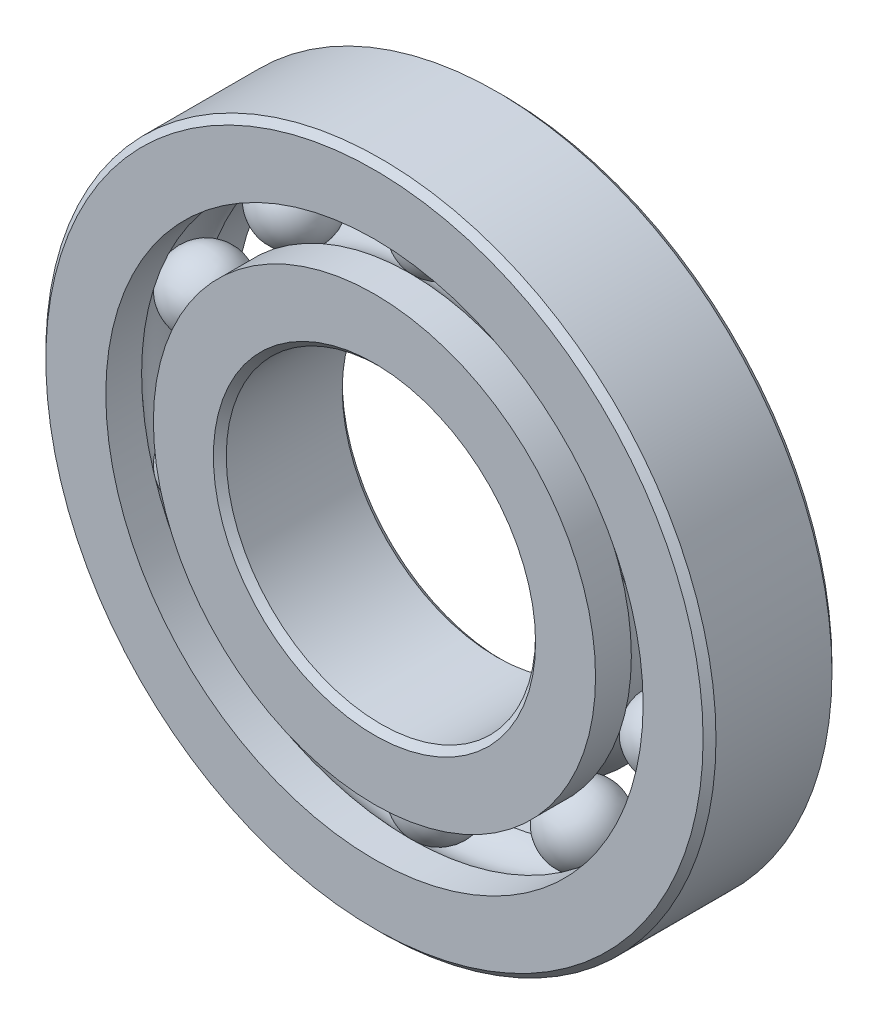
from build123d import *

# Parameters (mm, degrees)
CIRPATTERN1_COUNT = 10


with BuildPart() as part:
    # Sketch1 → Revolve1 (revolve)
    with BuildSketch(Plane(origin=(0, 0, 0), x_dir=(0, 0, -1), z_dir=(1, 0, 0)), mode=Mode.PRIVATE) as revolve1_sk:
        with BuildLine():
            Line((3.571875, 20.6375), (-3.571875, 20.6375))
            Line((-3.571875, 20.6375), (-3.96875, 20.240625))
            Line((-3.96875, 20.240625), (-3.96875, 16.546634615))
            Line((-3.96875, 16.546634615), (-1.763888889, 16.546634615))
            ThreePointArc((-1.763888889, 16.546634615), (0, 17.374425982), (1.763888889, 16.546634615))
            Line((1.763888889, 16.546634615), (3.96875, 16.546634615))
            Line((3.96875, 16.546634615), (3.96875, 20.240625))
            Line((3.96875, 20.240625), (3.571875, 20.6375))
        make_face()
    revolve(revolve1_sk.sketch.rotate(Axis((0, 0, 3.96875), (0, 0, -1)), 90), axis=Axis((0, 0, 3.96875), (0, 0, -1)))  # turned: the seam where the file's is


with BuildPart() as body_2:
    # Sketch3 → Revolve3 (revolve)
    with BuildSketch(Plane(origin=(0, 0, 0), x_dir=(0, 0, -1), z_dir=(1, 0, 0)), mode=Mode.PRIVATE) as revolve3_sk:
        with BuildLine():
            Line((-3.96875, 13.615865385), (-1.763888889, 13.615865385))
            ThreePointArc((-1.763888889, 13.615865385), (0, 12.788074018), (1.763888889, 13.615865385))
            Line((1.763888889, 13.615865385), (3.96875, 13.615865385))
            Line((3.96875, 13.615865385), (3.96875, 9.921875))
            Line((3.96875, 9.921875), (3.571875, 9.525))
            Line((3.571875, 9.525), (-3.571875, 9.525))
            Line((-3.571875, 9.525), (-3.96875, 9.921875))
            Line((-3.96875, 9.921875), (-3.96875, 13.615865385))
        make_face()
    revolve(revolve3_sk.sketch.rotate(Axis((0, 0, 3.96875), (0, 0, -1)), 90), axis=Axis((0, 0, 3.96875), (0, 0, -1)))  # turned: the seam where the file's is


with BuildPart() as body_3:
    # Sketch4 → Revolve4 (revolve)
    with BuildSketch(Plane(origin=(0, 0, 0), x_dir=(0, 0, -1), z_dir=(1, 0, 0))):
        with BuildLine():
            Line((-2.293175982, 15.08125), (2.293175982, 15.08125))
            ThreePointArc((2.293175982, 15.08125), (0, 17.374425982), (-2.293175982, 15.08125))
        make_face()
    revolve(axis=Axis((0, 15.08125, 2.293175982), (0, 0, -1)))


with BuildPart() as cirpattern1_1:
    # CirPattern1: pattern copy
    add(body_3.part.rotate(Axis((0, 0, 0), (0, 0, 1)), 1 * 360 / CIRPATTERN1_COUNT))


with BuildPart() as cirpattern1_2:
    # CirPattern1: pattern copy
    add(body_3.part.rotate(Axis((0, 0, 0), (0, 0, 1)), 2 * 360 / CIRPATTERN1_COUNT))


with BuildPart() as cirpattern1_3:
    # CirPattern1: pattern copy
    add(body_3.part.rotate(Axis((0, 0, 0), (0, 0, 1)), 3 * 360 / CIRPATTERN1_COUNT))


with BuildPart() as cirpattern1_4:
    # CirPattern1: pattern copy
    add(body_3.part.rotate(Axis((0, 0, 0), (0, 0, 1)), 4 * 360 / CIRPATTERN1_COUNT))


with BuildPart() as cirpattern1_5:
    # CirPattern1: pattern copy
    add(body_3.part.rotate(Axis((0, 0, 0), (0, 0, 1)), 5 * 360 / CIRPATTERN1_COUNT))


with BuildPart() as cirpattern1_6:
    # CirPattern1: pattern copy
    add(body_3.part.rotate(Axis((0, 0, 0), (0, 0, 1)), 6 * 360 / CIRPATTERN1_COUNT))


with BuildPart() as cirpattern1_7:
    # CirPattern1: pattern copy
    add(body_3.part.rotate(Axis((0, 0, 0), (0, 0, 1)), 7 * 360 / CIRPATTERN1_COUNT))


with BuildPart() as cirpattern1_8:
    # CirPattern1: pattern copy
    add(body_3.part.rotate(Axis((0, 0, 0), (0, 0, 1)), 8 * 360 / CIRPATTERN1_COUNT))


with BuildPart() as cirpattern1_9:
    # CirPattern1: pattern copy
    add(body_3.part.rotate(Axis((0, 0, 0), (0, 0, 1)), 9 * 360 / CIRPATTERN1_COUNT))


solid = Compound([part.part, body_2.part, body_3.part, cirpattern1_1.part, cirpattern1_2.part, cirpattern1_3.part, cirpattern1_4.part, cirpattern1_5.part, cirpattern1_6.part, cirpattern1_7.part, cirpattern1_8.part, cirpattern1_9.part])
